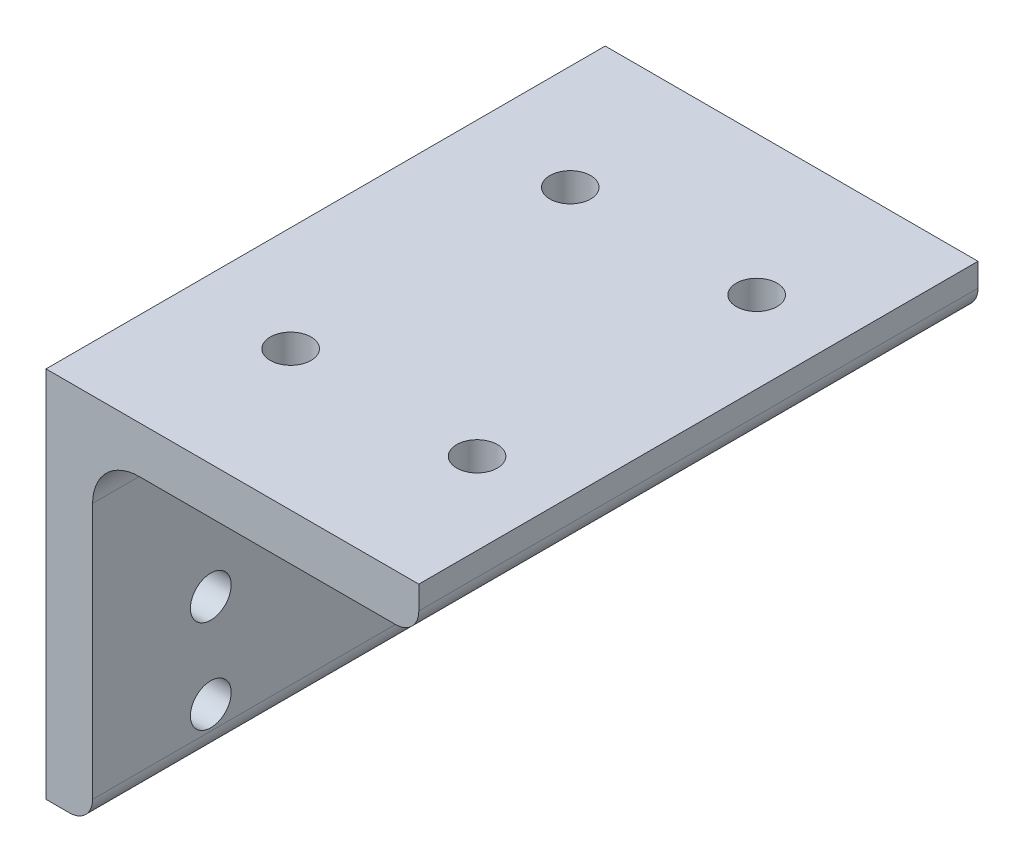
from build123d import *

# Parameters (mm, degrees)
EXTRUDE1_DEPTH                  = 38.1
F_7_32_0_21875_DIAMETER_HOLE2_D = 5.55625
F_7_32_0_21875_DIAMETER_HOLE3_D = 5.55625
SKETCH6_R                       = 6.35
CUT_EXTRUDE1_DEPTH              = 9.525


with BuildPart() as part:
    # Sketch1 → Extrude1 (new body, symmetric)
    with BuildSketch(Plane.XY):
        with BuildLine():
            Line((0, 0), (50.8, 0))
            Line((50.8, 0), (50.8, -3.175))
            ThreePointArc((50.8, -3.175), (49.87006403, -5.42006403), (47.625, -6.35))
            Line((47.625, -6.35), (12.7, -6.35))
            ThreePointArc((12.7, -6.35), (8.209871939, -8.209871939), (6.35, -12.7))
            Line((6.35, -12.7), (6.35, -47.625))
            ThreePointArc((6.35, -47.625), (5.42006403, -49.87006403), (3.175, -50.8))
            Line((3.175, -50.8), (0, -50.8))
            Line((0, -50.8), (0, 0))
        make_face()
    extrude(amount=EXTRUDE1_DEPTH, both=True)

    # 7/32 (0.21875) Diameter Hole2 (through all)
    with Locations(Plane(origin=(-45.24375, 0, 38.1), x_dir=(-1, 0, 0), z_dir=(0, 1, 0))):
        with Locations((-84.93125, -19.05), (-84.93125, -57.15), (-59.53125, -57.15), (-59.53125, -19.05)):
            Hole(F_7_32_0_21875_DIAMETER_HOLE2_D / 2)

    # 7/32 (0.21875) Diameter Hole3 (through all)
    with Locations(Plane(origin=(6.35, 0, 0), x_dir=(0, 0, -1), z_dir=(1, 0, 0))):
        with Locations((-21.9964, -15.875), (21.9964, -15.875), (21.9964, -44.45), (-21.9964, -44.45), (-21.9964, -31.75), (21.9964, -31.75)):
            Hole(F_7_32_0_21875_DIAMETER_HOLE3_D / 2)

    # Sketch6 → Cut-Extrude1 (cut)
    with BuildSketch(Plane(origin=(0, -15.875, 0), x_dir=(-1, 0, 0), z_dir=(0, 1, 0))):
        with Locations((-14.2875, 19.05)):
            Circle(SKETCH6_R)
        with Locations((-14.2875, -19.05)):
            Circle(SKETCH6_R)
    extrude(amount=CUT_EXTRUDE1_DEPTH, mode=Mode.SUBTRACT)


solid = part.part
